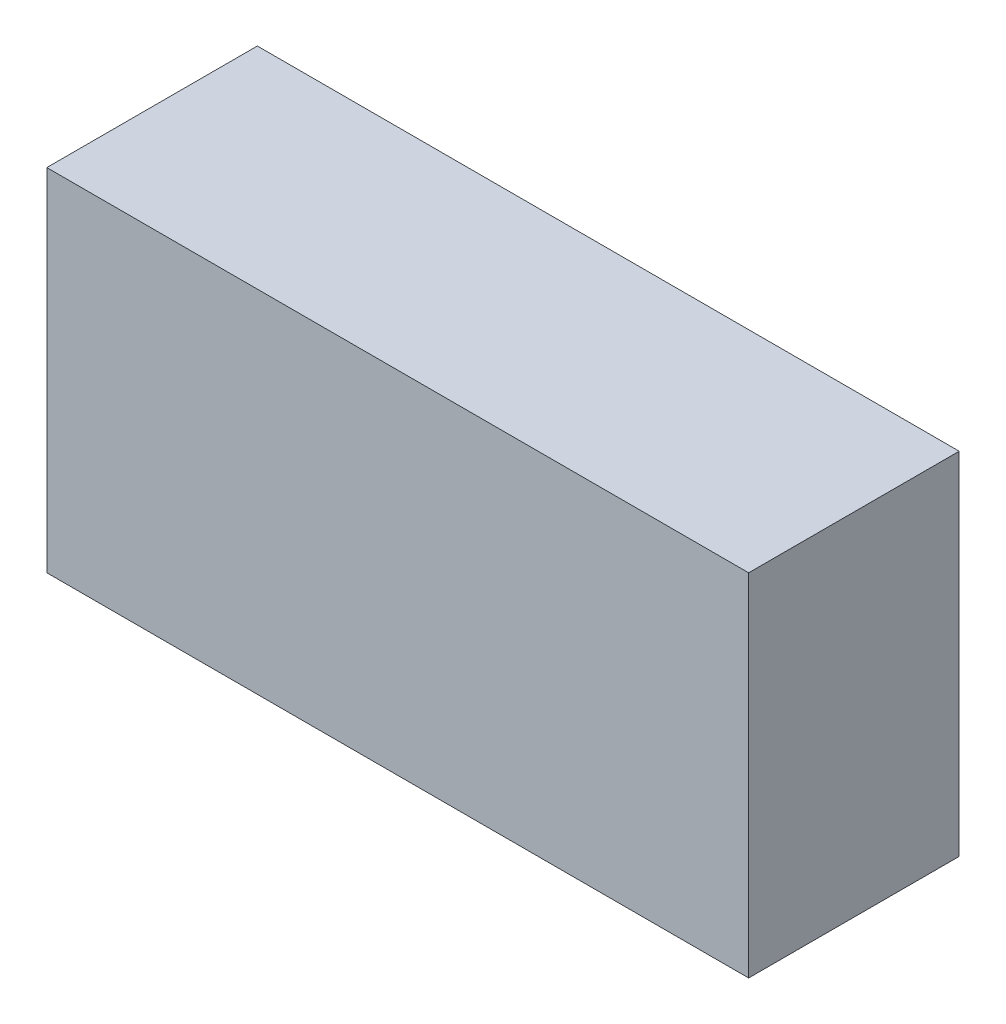
from build123d import *

# Parameters (mm, degrees)
SKETCH1_W           = 10
SKETCH1_H           = 5
BOSS_EXTRUDE1_DEPTH = 3


with BuildPart() as part:
    # Sketch1 → Boss-Extrude1 (new body)
    with BuildSketch(Plane.XY):
        Rectangle(SKETCH1_W, SKETCH1_H)
    extrude(amount=BOSS_EXTRUDE1_DEPTH)


solid = part.part
